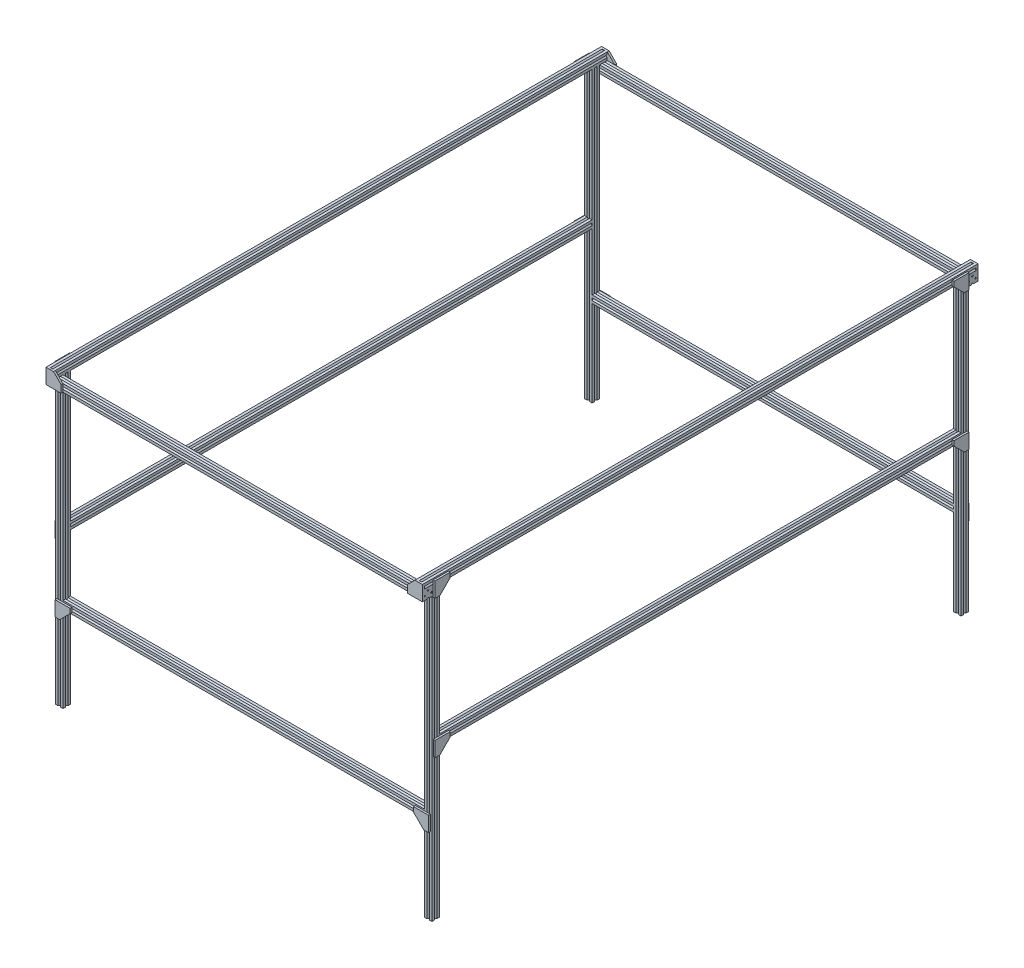
from build123d import *

# Parameters (mm, degrees)
VERTICAL_LEG_DEPTH               = 767.075
SHORT_HORIZONTAL_DEPTH           = 479.425
LONG_HORIZONTAL_DEPTH            = 692.15
LONG_HORIZONTAL_BACKWARDS_DEPTH  = 40
SHORT_HORIZONTAL_BACKWARDS_DEPTH = 20
BRACKETS_1_2_DEPTH               = 5
BRACKET_3_DEPTH                  = 5
BRACKET_4_DEPTH                  = 5


with BuildPart() as part:
    # Sketch1 → Vertical Leg (new body)
    with BuildSketch(Plane(origin=(0, 0, 0), x_dir=(1, 0, 0), z_dir=(0, 1, 0))):
        Polygon((0, 20), (-6.8, 20), (-10, 16.8), (-13.2, 20), (-20, 20), (-20, 13.2), (-16.8, 10), (-20, 6.8), (-20, 0), (-13.2, 0), (-10, 3.2), (-6.8, 0), (0, 0), (0, 6.8), (-3.2, 10), (0, 13.2), align=None)
    extrude(amount=VERTICAL_LEG_DEPTH)

    # Sketch2 → Short Horizontal (add)
    with BuildSketch(Plane.ZY.offset(20)):
        Polygon((-20, 235.4), (-20, 228.6), (-13.2, 228.6), (-10, 231.8), (-6.8, 228.6), (0, 228.6), (0, 235.4), (-3.2, 238.6), (0, 241.8), (0, 248.6), (-6.8, 248.6), (-10, 245.4), (-13.2, 248.6), (-20, 248.6), (-20, 241.8), (-16.8, 238.6), align=None)
        Polygon((0, 753.875), (0, 747.075), (6.8, 747.075), (10, 750.275), (13.2, 747.075), (20, 747.075), (20, 753.875), (16.8, 757.075), (20, 760.275), (20, 767.075), (13.2, 767.075), (10, 763.875), (6.8, 767.075), (0, 767.075), (0, 760.275), (3.2, 757.075), align=None)
    extrude(amount=SHORT_HORIZONTAL_DEPTH)


with BuildPart() as short_horizontal_piece_1:
    # of the separate pieces the step leaves, piece 1, a body of its own (short_horizontal_pieces)
    add(part.part.solids().sort_by_distance((-13.2, 0, 0))[0])

    # Sketch3 → Long Horizontal (add)
    with BuildSketch(Plane(origin=(0, 0, -20), x_dir=(-1, 0, 0), z_dir=(0, 0, -1))):
        Polygon((0, 407.8), (0, 401), (6.8, 401), (10, 404.2), (13.2, 401), (20, 401), (20, 407.8), (16.8, 411), (20, 414.2), (20, 421), (13.2, 421), (10, 417.8), (6.8, 421), (0, 421), (0, 414.2), (3.2, 411), align=None)
        Polygon((13.2, 767.075), (20, 767.075), (20, 773.875), (16.8, 777.075), (20, 780.275), (20, 787.075), (13.2, 787.075), (10, 783.875), (6.8, 787.075), (0, 787.075), (0, 780.275), (3.2, 777.075), (0, 773.875), (0, 767.075), (6.8, 767.075), (10, 770.275), align=None)
    extrude(amount=LONG_HORIZONTAL_DEPTH)


with BuildPart() as short_horizontal_piece_2:
    # of the separate pieces the step leaves, piece 2, a body of its own (short_horizontal_pieces)
    add(part.part.solids().sort_by_distance((-499.425, 753.875, 0))[0])



with BuildPart() as long_horizontal_piece_1:
    # of the separate pieces the step leaves, piece 1, a body of its own (long_horizontal_pieces)
    add(short_horizontal_piece_1.part.solids().sort_by_distance((-13.2, 0, 0))[0])


with BuildPart() as long_horizontal_piece_2:
    # of the separate pieces the step leaves, piece 2, a body of its own (long_horizontal_pieces)
    add(short_horizontal_piece_1.part.solids().sort_by_distance((0, 767.075, -712.15))[0])


    add(long_horizontal_piece_1.part)  # Long Horizontal Backwards merges Long Horizontal piece 1
    # Sketch3_3 → Long Horizontal Backwards (add)
    with BuildSketch(Plane(origin=(0, 0, -20), x_dir=(-1, 0, 0), z_dir=(0, 0, -1))):
        Polygon((0, 773.875), (0, 767.075), (6.8, 767.075), (10, 770.275), (13.2, 767.075), (20, 767.075), (20, 773.875), (16.8, 777.075), (20, 780.275), (20, 787.075), (13.2, 787.075), (10, 783.875), (6.8, 787.075), (0, 787.075), (0, 780.275), (3.2, 777.075), align=None)
    extrude(amount=-LONG_HORIZONTAL_BACKWARDS_DEPTH)


with BuildPart() as short_horizontal_piece_2_1:
    add(short_horizontal_piece_2.part)

    add(long_horizontal_piece_2.part)  # Short Horizontal Backwards merges Long Horizontal piece 2
    # Sketch2_3 → Short Horizontal Backwards (add)
    with BuildSketch(Plane.ZY.offset(20)):
        Polygon((0, 753.875), (0, 747.075), (6.8, 747.075), (10, 750.275), (13.2, 747.075), (20, 747.075), (20, 753.875), (16.8, 757.075), (20, 760.275), (20, 767.075), (13.2, 767.075), (10, 763.875), (6.8, 767.075), (0, 767.075), (0, 760.275), (3.2, 757.075), align=None)
    extrude(amount=-SHORT_HORIZONTAL_BACKWARDS_DEPTH)

    # Sketch4 → Brackets 1 _ 2 (add)
    with BuildSketch(Plane(origin=(0, 0, 0), x_dir=(0, 0, -1), z_dir=(1, 0, 0))):
        Polygon((3.509446778, 743.565553222), (16.490553222, 743.565553222), (43.509446778, 770.584446778), (43.509446778, 783.565553222), (3.509446778, 783.565553222), align=None)
        Polygon((3.854478715, 417.145521285), (43.854478715, 417.145521285), (43.854478715, 404.854478715), (16.145521285, 377.145521285), (3.854478715, 377.145521285), align=None)
    extrude(amount=BRACKETS_1_2_DEPTH)

    # Sketch5 → Bracket 3 (add)
    with BuildSketch(Plane.XY.offset(20)):
        Polygon((-40, 747.075), (-40, 767.075), (-20, 787.075), (0, 787.075), (0, 747.075), align=None)
    extrude(amount=BRACKET_3_DEPTH)

    # Sketch6 → Bracket 4 (add)
    with BuildSketch(Plane.XY):
        Polygon((-43.679581294, 244.920418706), (-43.679581294, 232.279581294), (-16.320418706, 204.920418706), (-3.679581294, 204.920418706), (-3.679581294, 244.920418706), align=None)
    extrude(amount=BRACKET_4_DEPTH)

    # Mirror1: Short Horizontal piece 2 across plane


with BuildPart() as short_horizontal_piece_2_2:
    add(short_horizontal_piece_2_1.part)
    add(short_horizontal_piece_2_1.part.mirror(Plane(origin=(0, 0, -712.15), x_dir=(1, 0, 0), z_dir=(0, 0, -1))))

    # Mirror2: Short Horizontal piece 2 across plane


with BuildPart() as short_horizontal_piece_2_3:
    add(short_horizontal_piece_2_2.part)
    add(short_horizontal_piece_2_2.part.mirror(Plane.ZY.offset(499.425)))


solid = short_horizontal_piece_2_3.part
